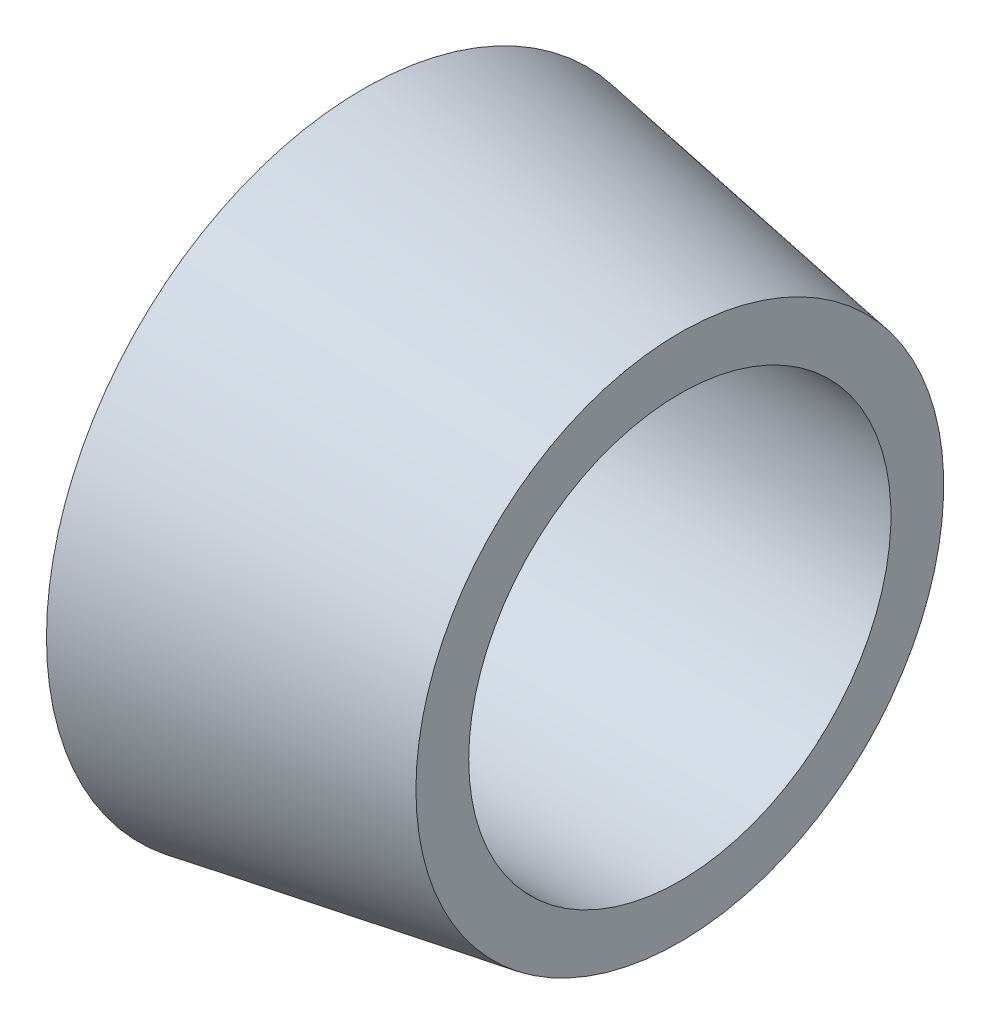
from build123d import *


with BuildPart() as part:
    # Szkic1 → Obrót1 (revolve)
    with BuildSketch(Plane.XY):
        Polygon((0, 4), (0, 6), (6, 5), (6, 4), align=None)
    revolve(axis=Axis((0, 0, 0), (1, 0, 0)))


solid = part.part
